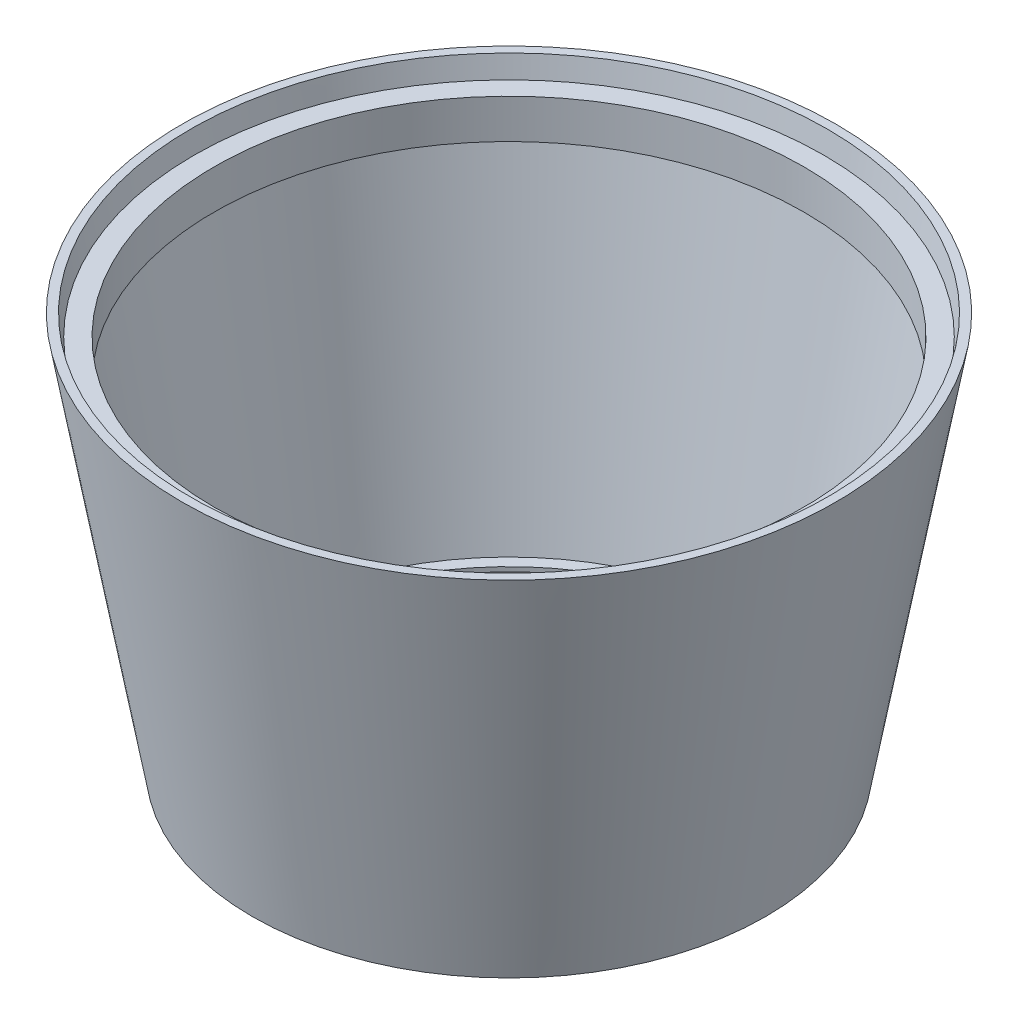
from build123d import *


with BuildPart() as part:
    # 草图1 → 旋转1 (revolve)
    with BuildSketch(Plane.XY):
        Polygon((0, 0), (50, 0), (269.922063783, 1231.604559039), (243.141809938, 1231.604559039), (231.609907229, 1167.023753883), (169.044056357, 1167.023753883), (169.044056357, 1044.492665553), (220.729405102, 1044.492665553), (36.718983853, 14), (0, 14), align=None)
    revolve(axis=Axis((-752, 0, 0), (0, 1, 0)))


solid = part.part
